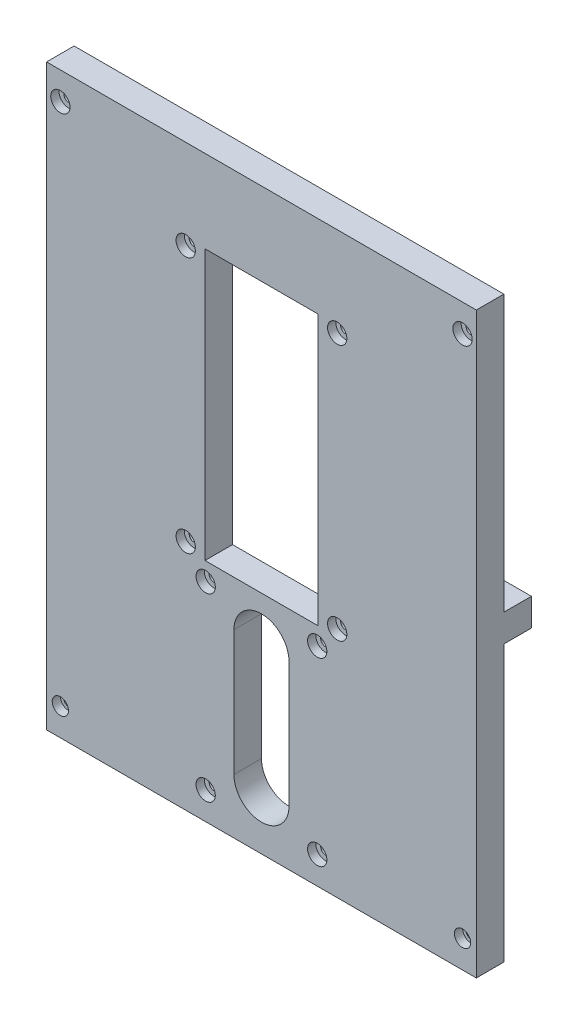
from build123d import *

# Parameters (mm, degrees)
SKETCH1_W               = 156
SKETCH1_H               = 210
BOSS_EXTRUDE1_DEPTH     = 10
SKETCH2_W               = 10
SKETCH2_H               = 10
BOSS_EXTRUDE2_DEPTH     = 10
SKETCH3_R               = 1.75
CUT_EXTRUDE1_DEPTH      = 11
CUT_EXTRUDE1_DEPTH_BACK = 11
CUT_EXTRUDE2_START      = 10
SKETCH4_R               = 3.5
SKETCH4_R_2             = 2.952582507
SKETCH4_R_3             = 2.953821107
CUT_EXTRUDE2_DEPTH      = 3
SKETCH5_R               = 1.75
SKETCH5_W               = 41
SKETCH5_H               = 98
CUT_EXTRUDE3_DEPTH      = 11
CUT_EXTRUDE3_DEPTH_BACK = 11
CUT_EXTRUDE4_START      = 10
SKETCH6_R               = 3.5
CUT_EXTRUDE4_DEPTH      = 3


with BuildPart() as part:
    # Sketch1 → Boss-Extrude1 (new body)
    with BuildSketch(Plane.XY):
        Rectangle(SKETCH1_W, SKETCH1_H)
    extrude(amount=BOSS_EXTRUDE1_DEPTH)

    # Sketch2 → Boss-Extrude2 (add)
    with BuildSketch(Plane.XY):
        with Locations((-73, 0)):
            Rectangle(SKETCH2_W, SKETCH2_H)
        with Locations((73, 0)):
            Rectangle(SKETCH2_W, SKETCH2_H)
    extrude(amount=-BOSS_EXTRUDE2_DEPTH)

    # Sketch3 → Cut-Extrude1 (cut, two sides)
    with BuildSketch(Plane.XY) as cut_extrude1_sk:
        with Locations((-73, 95)):
            Circle(SKETCH3_R)
        with Locations((73, 95)):
            Circle(SKETCH3_R)
        with Locations((73, -95)):
            Circle(SKETCH3_R)
        with Locations((-73, -95)):
            Circle(SKETCH3_R)
    extrude(amount=CUT_EXTRUDE1_DEPTH, mode=Mode.SUBTRACT)
    extrude(cut_extrude1_sk.sketch, amount=-CUT_EXTRUDE1_DEPTH_BACK, mode=Mode.SUBTRACT)

    # Sketch4 → Cut-Extrude2 (cut)
    with BuildSketch(Plane.XY.offset(CUT_EXTRUDE2_START)):
        with Locations((-73, 95)):
            Circle(SKETCH4_R)
        with Locations((73, 95)):
            Circle(SKETCH4_R)
        with Locations((73, -95)):
            Circle(SKETCH4_R_2)
        with Locations((-73, -95)):
            Circle(SKETCH4_R_3)
    extrude(amount=-CUT_EXTRUDE2_DEPTH, mode=Mode.SUBTRACT)

    # Sketch5 → Cut-Extrude3 (cut, two sides)
    with BuildSketch(Plane.XY) as cut_extrude3_sk:
        with Locations((-27.5, 72.5)):
            Circle(SKETCH5_R)
        with Locations((27.5, 72.5)):
            Circle(SKETCH5_R)
        with Locations((27.5, -20.5)):
            Circle(SKETCH5_R)
        with Locations((-27.5, -20.5)):
            Circle(SKETCH5_R)
        with Locations((-20.25, -29.5)):
            Circle(SKETCH5_R)
        with Locations((20.25, -29.5)):
            Circle(SKETCH5_R)
        with Locations((20.25, -95)):
            Circle(SKETCH5_R)
        with Locations((-20.25, -95)):
            Circle(SKETCH5_R)
        with Locations((0, 26)):
            Rectangle(SKETCH5_W, SKETCH5_H)
        with BuildLine():
            Line((10, -39.5), (10, -85))
            ThreePointArc((10, -85), (0, -95), (-10, -85))
            Line((-10, -85), (-10, -39.5))
            ThreePointArc((-10, -39.5), (0, -29.5), (10, -39.5))
        make_face()
    extrude(amount=CUT_EXTRUDE3_DEPTH, mode=Mode.SUBTRACT)
    extrude(cut_extrude3_sk.sketch, amount=-CUT_EXTRUDE3_DEPTH_BACK, mode=Mode.SUBTRACT)

    # Sketch6 → Cut-Extrude4 (cut)
    with BuildSketch(Plane.XY.offset(CUT_EXTRUDE4_START)):
        with Locations((-20.25, -95)):
            Circle(SKETCH6_R)
        with Locations((20.25, -95)):
            Circle(SKETCH6_R)
        with Locations((20.25, -29.5)):
            Circle(SKETCH6_R)
        with Locations((-20.25, -29.5)):
            Circle(SKETCH6_R)
        with Locations((27.5, -20.5)):
            Circle(SKETCH6_R)
        with Locations((-27.5, -20.5)):
            Circle(SKETCH6_R)
        with Locations((-27.5, 72.5)):
            Circle(SKETCH6_R)
        with Locations((27.5, 72.5)):
            Circle(SKETCH6_R)
    extrude(amount=-CUT_EXTRUDE4_DEPTH, mode=Mode.SUBTRACT)


solid = part.part
